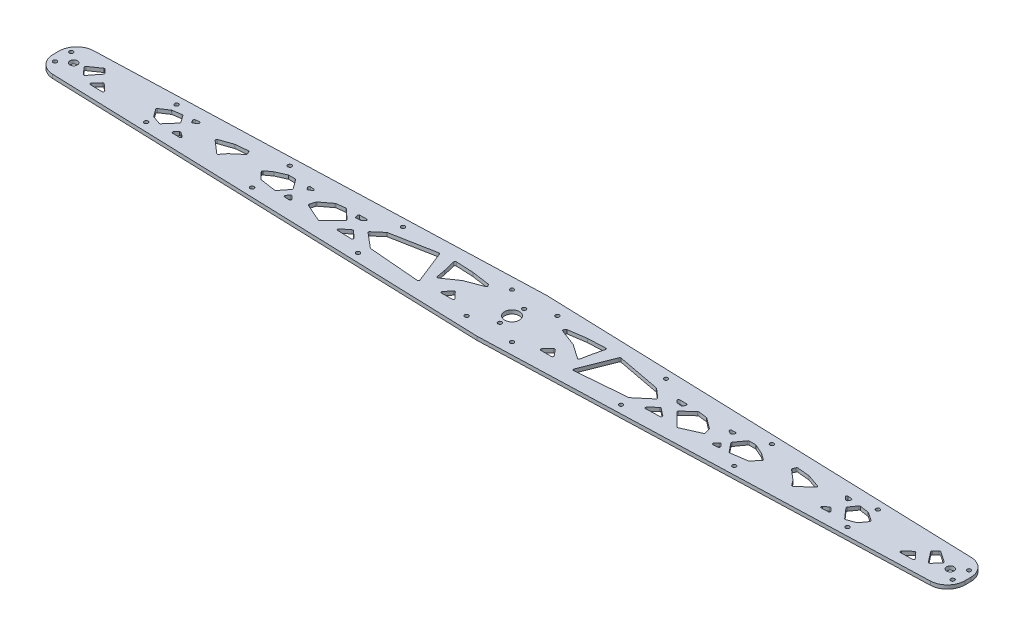
from build123d import *

# Parameters (mm, degrees)
BOSS_EXTRUDE1_DEPTH = 3.18
SKETCH3_R           = 6.35
SKETCH3_R_2         = 3.175
SKETCH3_R_3         = 1.65
CUT_EXTRUDE1_DEPTH  = 4.18
CUT_EXTRUDE8_DEPTH  = 4.18
SKETCH12_R          = 1.65
CUT_EXTRUDE9_DEPTH  = 4.18


with BuildPart() as part:
    # Sketch2 → Boss-Extrude1 (new body)
    with BuildSketch(Plane(origin=(0, 0, 0), x_dir=(1, 0, 0), z_dir=(0, 1, 0))):
        with BuildLine():
            Line((-375, 17.5), (0, 30))
            Line((0, 30), (375, 17.5))
            Line((375, 17.5), (375.499722453, 17.483342585))
            ThreePointArc((375.499722453, 17.483342585), (385.781832794, 12.920095592), (390, 2.49166898))
            Line((390, 2.49166898), (390, -2.49166898))
            ThreePointArc((390, -2.49166898), (385.781832794, -12.920095592), (375.499722453, -17.483342585))
            Line((375.499722453, -17.483342585), (375, -17.5))
            Line((375, -17.5), (0, -30))
            Line((0, -30), (-375, -17.5))
            Line((-375, -17.5), (-375.499722453, -17.483342585))
            ThreePointArc((-375.499722453, -17.483342585), (-385.781832794, -12.920095592), (-390, -2.49166898))
            Line((-390, -2.49166898), (-390, 2.49166898))
            ThreePointArc((-390, 2.49166898), (-385.781832794, 12.920095592), (-375.499722453, 17.483342585))
            Line((-375.499722453, 17.483342585), (-375, 17.5))
        make_face()
    extrude(amount=BOSS_EXTRUDE1_DEPTH)

    # Sketch3 → Cut-Extrude1 (cut, through all)
    with BuildSketch(Plane(origin=(0, 3.18, 0), x_dir=(1, 0, 0), z_dir=(0, 1, 0))):
        Circle(SKETCH3_R)
        with Locations((-375, 0)):
            Circle(SKETCH3_R_2)
        with Locations((-206.25, 16.125)):
            Circle(SKETCH3_R_3)
        with Locations((-112.5, -19.25)):
            Circle(SKETCH3_R_3)
        with Locations((375, 0)):
            Circle(SKETCH3_R_2)
        with Locations((-112.5, 19.25)):
            Circle(SKETCH3_R_3)
        with Locations((-206.25, -16.125)):
            Circle(SKETCH3_R_3)
        with Locations((112.5, -19.25)):
            Circle(SKETCH3_R_3)
        with Locations((112.5, 19.25)):
            Circle(SKETCH3_R_3)
        with Locations((206.25, -16.125)):
            Circle(SKETCH3_R_3)
        with Locations((206.25, 16.125)):
            Circle(SKETCH3_R_3)
        with Locations((-384, 7)):
            Circle(SKETCH3_R_3)
        with Locations((-384, -7)):
            Circle(SKETCH3_R_3)
        with Locations((384, -7)):
            Circle(SKETCH3_R_3)
        with Locations((384, 7)):
            Circle(SKETCH3_R_3)
        with Locations((-19.420687745, 19.420687745)):
            Circle(SKETCH3_R_3)
        with Locations((-19.420687745, -19.420687745)):
            Circle(SKETCH3_R_3)
        with Locations((19.420687745, -19.420687745)):
            Circle(SKETCH3_R_3)
        with Locations((19.420687745, 19.420687745)):
            Circle(SKETCH3_R_3)
        with Locations((-300, 13)):
            Circle(SKETCH3_R_3)
        with Locations((-300, -13)):
            Circle(SKETCH3_R_3)
        with Locations((300, -13)):
            Circle(SKETCH3_R_3)
        with Locations((300, 13)):
            Circle(SKETCH3_R_3)
    extrude(amount=-CUT_EXTRUDE1_DEPTH, mode=Mode.SUBTRACT)

    # Sketch11 → Cut-Extrude8 (cut, through all)
    with BuildSketch(Plane(origin=(0, 3.18, 0), x_dir=(1, 0, 0), z_dir=(0, 1, 0))):
        with BuildLine():
            Line((-46.955749346, -13.254199403), (-37.87504075, -13.254199403))
            ThreePointArc((-37.87504075, -13.254199403), (-36.95455324, -12.644971387), (-37.155639289, -11.559604889))
            Line((-37.155639289, -11.559604889), (-42.067554645, -6.472263986))
            ThreePointArc((-42.067554645, -6.472263986), (-42.827630249, -6.167686035), (-43.560434546, -6.533035888))
            Line((-43.560434546, -6.533035888), (-47.729227786, -11.620376792))
            ThreePointArc((-47.729227786, -11.620376792), (-47.859580804, -12.68208805), (-46.955749346, -13.254199403))
        make_face()
        with BuildLine():
            Line((-59.536816501, -3.515356838), (-47.468549241, 4.898167025))
            ThreePointArc((-47.468549241, 4.898167025), (-47.363497956, 4.962180575), (-47.251381641, 5.012810987))
            Line((-47.251381641, 5.012810987), (-32.914496504, 10.452279602))
            ThreePointArc((-32.914496504, 10.452279602), (-32.313794994, 11.092037289), (-32.44890253, 11.959146368))
            Line((-32.44890253, 11.959146368), (-33.152492574, 12.968368286))
            ThreePointArc((-33.152492574, 12.968368286), (-33.448046335, 13.247713619), (-33.830389761, 13.386275322))
            Line((-33.830389761, 13.386275322), (-49.020035845, 15.571979867))
            ThreePointArc((-49.020035845, 15.571979867), (-49.06816555, 15.57771866), (-49.116516797, 15.58111852))
            Line((-49.116516797, 15.58111852), (-63.942588973, 16.263044091))
            ThreePointArc((-63.942588973, 16.263044091), (-64.760029141, 15.900337127), (-64.960455814, 15.028790273))
            Line((-64.960455814, 15.028790273), (-62.531576105, 4.996583503))
            ThreePointArc((-62.531576105, 4.996583503), (-62.52527538, 4.968839122), (-62.519766476, 4.940926727))
            Line((-62.519766476, 4.940926727), (-61.092444735, -2.874685387))
            ThreePointArc((-61.092444735, -2.874685387), (-60.48952482, -3.619685515), (-59.536816501, -3.515356838))
        make_face()
        with BuildLine():
            Line((-65.867489279, -12.851084643), (-76.818791516, 14.810968515))
            ThreePointArc((-76.818791516, 14.810968515), (-77.266092019, 15.318773143), (-77.93434379, 15.42546359))
            Line((-77.93434379, 15.42546359), (-114.979478259, 8.421844862))
            ThreePointArc((-114.979478259, 8.421844862), (-115.227740664, 8.340150133), (-115.44635537, 8.196916545))
            Line((-115.44635537, 8.196916545), (-123.167009838, 1.546451805))
            ThreePointArc((-123.167009838, 1.546451805), (-123.514354617, 0.783798146), (-123.159419133, 0.024647435))
            Line((-123.159419133, 0.024647435), (-110.862565184, -10.35581369))
            ThreePointArc((-110.862565184, -10.35581369), (-110.599754836, -10.515737447), (-110.300767263, -10.588203424))
            Line((-110.300767263, -10.588203424), (-66.880530036, -14.21571199))
            ThreePointArc((-66.880530036, -14.21571199), (-65.994339866, -13.81524887), (-65.867489279, -12.851084643))
        make_face()
        with BuildLine():
            Line((-138.500363881, -9.512051857), (-132.205638285, -4.609617592))
            ThreePointArc((-132.205638285, -4.609617592), (-131.548188505, -4.399497492), (-130.911222966, -4.665327458))
            Line((-130.911222966, -4.665327458), (-125.244008956, -9.920736989))
            ThreePointArc((-125.244008956, -9.920736989), (-124.998535496, -11.032881643), (-125.953468681, -11.653547063))
            Line((-125.953468681, -11.653547063), (-137.915408287, -11.300571796))
            ThreePointArc((-137.915408287, -11.300571796), (-138.836369454, -10.611864392), (-138.500363881, -9.512051857))
        make_face()
        with BuildLine():
            Line((-139.739839999, 9.466665143), (-133.930891567, 9.592555667))
            ThreePointArc((-133.930891567, 9.592555667), (-132.974208512, 8.947395111), (-133.262475942, 7.83008741))
            Line((-133.262475942, 7.83008741), (-134.995827799, 6.360257908))
            ThreePointArc((-134.995827799, 6.360257908), (-135.241086847, 6.207097438), (-135.519914513, 6.130512433))
            Line((-135.519914513, 6.130512433), (-138.979079647, 5.70297517))
            ThreePointArc((-138.979079647, 5.70297517), (-139.629939754, 5.846302376), (-140.046194638, 6.366776619))
            Line((-140.046194638, 6.366776619), (-140.662626079, 8.138252861))
            ThreePointArc((-140.662626079, 8.138252861), (-140.539462824, 9.037411465), (-139.739839999, 9.466665143))
        make_face()
        with BuildLine():
            Line((-141.869121283, 0.703843181), (-150.293270264, 8.561291761))
            ThreePointArc((-150.293270264, 8.561291761), (-150.668059683, 8.78163118), (-151.100932501, 8.822099584))
            Line((-151.100932501, 8.822099584), (-158.46185294, 7.890337503))
            ThreePointArc((-158.46185294, 7.890337503), (-158.713075968, 7.824547363), (-158.938886877, 7.696286749))
            Line((-158.938886877, 7.696286749), (-167.835601055, 0.978159169))
            ThreePointArc((-167.835601055, 0.978159169), (-168.05379305, 0.751333346), (-168.190677878, 0.467925082))
            Line((-168.190677878, 0.467925082), (-169.532071457, -3.995753156))
            ThreePointArc((-169.532071457, -3.995753156), (-169.482672907, -4.701887684), (-168.978159747, -5.198408239))
            Line((-168.978159747, -5.198408239), (-153.825057905, -11.886351336))
            ThreePointArc((-153.825057905, -11.886351336), (-153.235786306, -11.95414059), (-152.711777672, -11.676199315))
            Line((-152.711777672, -11.676199315), (-141.841702337, -0.7321369))
            ThreePointArc((-141.841702337, -0.7321369), (-141.551385579, -0.00834171), (-141.869121283, 0.703843181))
        make_face()
        with BuildLine():
            Line((-182.755031755, -5.299067981), (-180.579398257, -7.823296737))
            ThreePointArc((-180.579398257, -7.823296737), (-180.443829145, -8.926135869), (-181.410839593, -9.473423661))
            Line((-181.410839593, -9.473423661), (-185.439828424, -9.174588009))
            ThreePointArc((-185.439828424, -9.174588009), (-186.28646803, -8.567815923), (-186.134274883, -7.537375127))
            Line((-186.134274883, -7.537375127), (-184.280919551, -5.311982023))
            ThreePointArc((-184.280919551, -5.311982023), (-183.520967893, -4.951970116), (-182.755031755, -5.299067981))
        make_face()
        with BuildLine():
            Line((-180.487436758, 6.129209035), (-178.34410904, 7.407639798))
            ThreePointArc((-178.34410904, 7.407639798), (-177.88764506, 8.514589055), (-178.82004379, 9.265807153))
            Line((-178.82004379, 9.265807153), (-181.742763405, 9.372060074))
            ThreePointArc((-181.742763405, 9.372060074), (-182.63306088, 8.893046831), (-182.650532608, 7.882216471))
            Line((-182.650532608, 7.882216471), (-181.871140711, 6.497532787))
            ThreePointArc((-181.871140711, 6.497532787), (-181.256931343, 6.02168626), (-180.487436758, 6.129209035))
        make_face()
        with BuildLine():
            Line((-193.789039066, -8.041405278), (-187.852068886, -0.594564861))
            ThreePointArc((-187.852068886, -0.594564861), (-187.634249822, 0.00587827), (-187.824300509, 0.615679742))
            Line((-187.824300509, 0.615679742), (-193.434660528, 8.356209406))
            ThreePointArc((-193.434660528, 8.356209406), (-193.789848688, 8.660094071), (-194.244346721, 8.76934633))
            Line((-194.244346721, 8.76934633), (-199.70292112, 8.76934633))
            ThreePointArc((-199.70292112, 8.76934633), (-199.909407573, 8.74779579), (-200.106994237, 8.68407302))
            Line((-200.106994237, 8.68407302), (-208.420259277, 5.011755427))
            ThreePointArc((-208.420259277, 5.011755427), (-208.514430087, 4.964065639), (-208.603049236, 4.90671493))
            Line((-208.603049236, 4.90671493), (-213.928370429, 1.046905536))
            ThreePointArc((-213.928370429, 1.046905536), (-214.336865254, 0.333462004), (-214.072627838, -0.445029026))
            Line((-214.072627838, -0.445029026), (-208.756796528, -6.141654092))
            ThreePointArc((-208.756796528, -6.141654092), (-208.489458004, -6.345355097), (-208.169728821, -6.448975729))
            Line((-208.169728821, -6.448975729), (-194.715009659, -8.407593757))
            ThreePointArc((-194.715009659, -8.407593757), (-194.203204992, -8.347947697), (-193.789039066, -8.041405278))
        make_face()
        with BuildLine():
            Line((-256.671139357, 4.718751255), (-245.67497638, 8.531374359))
            ThreePointArc((-245.67497638, 8.531374359), (-245.560909702, 8.563492446), (-245.443844553, 8.581891611))
            Line((-245.443844553, 8.581891611), (-235.114669132, 9.582900663))
            ThreePointArc((-235.114669132, 9.582900663), (-234.507333866, 9.447217919), (-234.097843596, 8.978620382))
            Line((-234.097843596, 8.978620382), (-233.190223738, 6.842502951))
            ThreePointArc((-233.190223738, 6.842502951), (-233.137214687, 6.222230535), (-233.461435256, 5.690790178))
            Line((-233.461435256, 5.690790178), (-241.684376578, -1.326788715))
            ThreePointArc((-241.684376578, -1.326788715), (-241.760643057, -1.399139955), (-241.828892701, -1.479097843))
            Line((-241.828892701, -1.479097843), (-245.184318041, -5.856705737))
            ThreePointArc((-245.184318041, -5.856705737), (-245.877859549, -6.24333317), (-246.634530886, -6.002648555))
            Line((-246.634530886, -6.002648555), (-257.000090234, 3.019641763))
            ThreePointArc((-257.000090234, 3.019641763), (-257.325318633, 3.964004117), (-256.671139357, 4.718751255))
        make_face()
        with BuildLine():
            Line((-281.137073769, -8.153694647), (-278.818258184, -5.834879062))
            ThreePointArc((-278.818258184, -5.834879062), (-278.197065936, -5.545683332), (-277.535535613, -5.724265559))
            Line((-277.535535613, -5.724265559), (-273.998540412, -8.214053722))
            ThreePointArc((-273.998540412, -8.214053722), (-273.625321962, -9.34754859), (-274.603340844, -10.031348044))
            Line((-274.603340844, -10.031348044), (-280.459151631, -9.860375466))
            ThreePointArc((-280.459151631, -9.860375466), (-281.359332965, -9.229961123), (-281.137073769, -8.153694647))
        make_face()
        with BuildLine():
            Line((-280.723932944, 9.802625591), (-277.488789213, 10.127315226))
            ThreePointArc((-277.488789213, 10.127315226), (-276.467186027, 9.520118535), (-276.747414613, 8.365201728))
            Line((-276.747414613, 8.365201728), (-279.104707894, 6.393867718))
            ThreePointArc((-279.104707894, 6.393867718), (-279.937308548, 6.179406901), (-280.628653906, 6.690541801))
            Line((-280.628653906, 6.690541801), (-281.506504356, 8.337186176))
            ThreePointArc((-281.506504356, 8.337186176), (-281.506173293, 9.278682803), (-280.723932944, 9.802625591))
        make_face()
        with BuildLine():
            Line((-290.168206163, 8.025157975), (-297.744296977, 6.8636667))
            ThreePointArc((-297.744296977, 6.8636667), (-297.954032467, 6.807674803), (-298.146743207, 6.707741631))
            Line((-298.146743207, 6.707741631), (-305.204875906, 2.011065969))
            ThreePointArc((-305.204875906, 2.011065969), (-305.634726846, 1.357607704), (-305.462686612, 0.594599387))
            Line((-305.462686612, 0.594599387), (-301.147906841, -5.403825691))
            ThreePointArc((-301.147906841, -5.403825691), (-300.937309283, -5.618984629), (-300.672216228, -5.761709442))
            Line((-300.672216228, -5.761709442), (-293.667939867, -8.26130378))
            ThreePointArc((-293.667939867, -8.26130378), (-293.079312884, -8.287070959), (-292.57834751, -7.976942974))
            Line((-292.57834751, -7.976942974), (-285.112364404, 0.57945318))
            ThreePointArc((-285.112364404, 0.57945318), (-284.867009214, 1.188798819), (-285.052655481, 1.818907335))
            Line((-285.052655481, 1.818907335), (-289.203471205, 7.618697534))
            ThreePointArc((-289.203471205, 7.618697534), (-289.628401701, 7.958254589), (-290.168206163, 8.025157975))
        make_face()
        with BuildLine():
            Line((-360.721388989, -4.456205516), (-353.816399288, 4.292749779))
            ThreePointArc((-353.816399288, 4.292749779), (-353.602294182, 4.955196144), (-353.872418696, 5.596841629))
            Line((-353.872418696, 5.596841629), (-356.779527483, 8.692466622))
            ThreePointArc((-356.779527483, 8.692466622), (-357.402501606, 9.002272333), (-358.07677814, 8.830727899))
            Line((-358.07677814, 8.830727899), (-367.037687971, 2.641731163))
            ThreePointArc((-367.037687971, 2.641731163), (-367.461830786, 1.941643396), (-367.221019381, 1.159320012))
            Line((-367.221019381, 1.159320012), (-362.257990463, -4.496263538))
            ThreePointArc((-362.257990463, -4.496263538), (-361.480302142, -4.836336586), (-360.721388989, -4.456205516))
        make_face()
        with BuildLine():
            Line((-352.372806931, -7.394203651), (-347.919490428, -2.485222451))
            ThreePointArc((-347.919490428, -2.485222451), (-347.227457966, -2.158301193), (-346.506948881, -2.416473802))
            Line((-346.506948881, -2.416473802), (-340.919616542, -7.485175085))
            ThreePointArc((-340.919616542, -7.485175085), (-340.661495607, -8.593335713), (-341.607418325, -9.225693685))
            Line((-341.607418325, -9.225693685), (-351.648067167, -9.065973602))
            ThreePointArc((-351.648067167, -9.065973602), (-352.549656155, -8.463848976), (-352.372806931, -7.394203651))
        make_face()
        with BuildLine():
            Line((37.155639289, -11.559604889), (42.067554645, -6.472263986))
            ThreePointArc((42.067554645, -6.472263986), (42.827630249, -6.167686035), (43.560434546, -6.533035888))
            Line((43.560434546, -6.533035888), (47.729227786, -11.620376792))
            ThreePointArc((47.729227786, -11.620376792), (47.859580804, -12.68208805), (46.955749346, -13.254199403))
            Line((46.955749346, -13.254199403), (37.87504075, -13.254199403))
            ThreePointArc((37.87504075, -13.254199403), (36.95455324, -12.644971387), (37.155639289, -11.559604889))
        make_face()
        with BuildLine():
            Line((64.960455814, 15.028790273), (62.531576105, 4.996583503))
            ThreePointArc((62.531576105, 4.996583503), (62.52527538, 4.968839122), (62.519766476, 4.940926727))
            Line((62.519766476, 4.940926727), (61.092444735, -2.874685387))
            ThreePointArc((61.092444735, -2.874685387), (60.48952482, -3.619685515), (59.536816501, -3.515356838))
            Line((59.536816501, -3.515356838), (47.468549241, 4.898167025))
            ThreePointArc((47.468549241, 4.898167025), (47.363497956, 4.962180575), (47.251381641, 5.012810987))
            Line((47.251381641, 5.012810987), (32.914496504, 10.452279602))
            ThreePointArc((32.914496504, 10.452279602), (32.313794994, 11.092037289), (32.44890253, 11.959146368))
            Line((32.44890253, 11.959146368), (33.152492574, 12.968368286))
            ThreePointArc((33.152492574, 12.968368286), (33.448046335, 13.247713619), (33.830389761, 13.386275322))
            Line((33.830389761, 13.386275322), (49.020035845, 15.571979867))
            ThreePointArc((49.020035845, 15.571979867), (49.06816555, 15.57771866), (49.116516797, 15.58111852))
            Line((49.116516797, 15.58111852), (63.942588973, 16.263044091))
            ThreePointArc((63.942588973, 16.263044091), (64.760029141, 15.900337127), (64.960455814, 15.028790273))
        make_face()
        with BuildLine():
            Line((123.159419133, 0.024647435), (110.862565184, -10.35581369))
            ThreePointArc((110.862565184, -10.35581369), (110.599754836, -10.515737447), (110.300767263, -10.588203424))
            Line((110.300767263, -10.588203424), (66.880530036, -14.21571199))
            ThreePointArc((66.880530036, -14.21571199), (65.994339866, -13.81524887), (65.867489279, -12.851084643))
            Line((65.867489279, -12.851084643), (76.818791516, 14.810968515))
            ThreePointArc((76.818791516, 14.810968515), (77.266092019, 15.318773143), (77.93434379, 15.42546359))
            Line((77.93434379, 15.42546359), (114.979478259, 8.421844862))
            ThreePointArc((114.979478259, 8.421844862), (115.227740664, 8.340150133), (115.44635537, 8.196916545))
            Line((115.44635537, 8.196916545), (123.167009838, 1.546451805))
            ThreePointArc((123.167009838, 1.546451805), (123.514354617, 0.783798146), (123.159419133, 0.024647435))
        make_face()
        with BuildLine():
            Line((135.519914513, 6.130512433), (138.979079647, 5.70297517))
            ThreePointArc((138.979079647, 5.70297517), (139.629939754, 5.846302376), (140.046194638, 6.366776619))
            Line((140.046194638, 6.366776619), (140.662626079, 8.138252861))
            ThreePointArc((140.662626079, 8.138252861), (140.539462824, 9.037411465), (139.739839999, 9.466665143))
            Line((139.739839999, 9.466665143), (133.930891567, 9.592555667))
            ThreePointArc((133.930891567, 9.592555667), (132.974208512, 8.947395111), (133.262475942, 7.83008741))
            Line((133.262475942, 7.83008741), (134.995827799, 6.360257908))
            ThreePointArc((134.995827799, 6.360257908), (135.241086847, 6.207097438), (135.519914513, 6.130512433))
        make_face()
        with BuildLine():
            Line((130.911222966, -4.665327458), (125.244008956, -9.920736989))
            ThreePointArc((125.244008956, -9.920736989), (124.998535496, -11.032881643), (125.953468681, -11.653547063))
            Line((125.953468681, -11.653547063), (137.915408287, -11.300571796))
            ThreePointArc((137.915408287, -11.300571796), (138.836369454, -10.611864392), (138.500363881, -9.512051857))
            Line((138.500363881, -9.512051857), (132.205638285, -4.609617592))
            ThreePointArc((132.205638285, -4.609617592), (131.548188505, -4.399497492), (130.911222966, -4.665327458))
        make_face()
        with BuildLine():
            Line((168.978159747, -5.198408239), (153.825057905, -11.886351336))
            ThreePointArc((153.825057905, -11.886351336), (153.235786306, -11.95414059), (152.711777672, -11.676199315))
            Line((152.711777672, -11.676199315), (141.841702337, -0.7321369))
            ThreePointArc((141.841702337, -0.7321369), (141.551385579, -0.00834171), (141.869121283, 0.703843181))
            Line((141.869121283, 0.703843181), (150.293270264, 8.561291761))
            ThreePointArc((150.293270264, 8.561291761), (150.668059683, 8.78163118), (151.100932501, 8.822099584))
            Line((151.100932501, 8.822099584), (158.46185294, 7.890337503))
            ThreePointArc((158.46185294, 7.890337503), (158.713075968, 7.824547363), (158.938886877, 7.696286749))
            Line((158.938886877, 7.696286749), (167.835601055, 0.978159169))
            ThreePointArc((167.835601055, 0.978159169), (168.05379305, 0.751333346), (168.190677878, 0.467925082))
            Line((168.190677878, 0.467925082), (169.532071457, -3.995753156))
            ThreePointArc((169.532071457, -3.995753156), (169.482672907, -4.701887684), (168.978159747, -5.198408239))
        make_face()
        with BuildLine():
            Line((181.871140711, 6.497532787), (182.650532608, 7.882216471))
            ThreePointArc((182.650532608, 7.882216471), (182.63306088, 8.893046831), (181.742763405, 9.372060074))
            Line((181.742763405, 9.372060074), (178.82004379, 9.265807153))
            ThreePointArc((178.82004379, 9.265807153), (177.88764506, 8.514589055), (178.34410904, 7.407639798))
            Line((178.34410904, 7.407639798), (180.487436758, 6.129209035))
            ThreePointArc((180.487436758, 6.129209035), (181.256931343, 6.02168626), (181.871140711, 6.497532787))
        make_face()
        with BuildLine():
            Line((181.410839593, -9.473423661), (185.439828424, -9.174588009))
            ThreePointArc((185.439828424, -9.174588009), (186.28646803, -8.567815923), (186.134274883, -7.537375127))
            Line((186.134274883, -7.537375127), (184.280919551, -5.311982023))
            ThreePointArc((184.280919551, -5.311982023), (183.520967893, -4.951970116), (182.755031755, -5.299067981))
            Line((182.755031755, -5.299067981), (180.579398257, -7.823296737))
            ThreePointArc((180.579398257, -7.823296737), (180.443829145, -8.926135869), (181.410839593, -9.473423661))
        make_face()
        with BuildLine():
            Line((214.072627838, -0.445029026), (208.756796528, -6.141654092))
            ThreePointArc((208.756796528, -6.141654092), (208.489458004, -6.345355097), (208.169728821, -6.448975729))
            Line((208.169728821, -6.448975729), (194.715009659, -8.407593757))
            ThreePointArc((194.715009659, -8.407593757), (194.203204992, -8.347947697), (193.789039066, -8.041405278))
            Line((193.789039066, -8.041405278), (187.852068886, -0.594564861))
            ThreePointArc((187.852068886, -0.594564861), (187.634249822, 0.00587827), (187.824300509, 0.615679742))
            Line((187.824300509, 0.615679742), (193.434660528, 8.356209406))
            ThreePointArc((193.434660528, 8.356209406), (193.789848688, 8.660094071), (194.244346721, 8.76934633))
            Line((194.244346721, 8.76934633), (199.70292112, 8.76934633))
            ThreePointArc((199.70292112, 8.76934633), (199.909407573, 8.74779579), (200.106994237, 8.68407302))
            Line((200.106994237, 8.68407302), (208.420259277, 5.011755427))
            ThreePointArc((208.420259277, 5.011755427), (208.514430087, 4.964065639), (208.603049236, 4.90671493))
            Line((208.603049236, 4.90671493), (213.928370429, 1.046905536))
            ThreePointArc((213.928370429, 1.046905536), (214.336865254, 0.333462004), (214.072627838, -0.445029026))
        make_face()
        with BuildLine():
            Line((241.828892701, -1.479097843), (245.184318041, -5.856705737))
            ThreePointArc((245.184318041, -5.856705737), (245.877859549, -6.24333317), (246.634530886, -6.002648555))
            Line((246.634530886, -6.002648555), (257.000090234, 3.019641763))
            ThreePointArc((257.000090234, 3.019641763), (257.325318633, 3.964004117), (256.671139357, 4.718751255))
            Line((256.671139357, 4.718751255), (245.67497638, 8.531374359))
            ThreePointArc((245.67497638, 8.531374359), (245.560909702, 8.563492446), (245.443844553, 8.581891611))
            Line((245.443844553, 8.581891611), (235.114669132, 9.582900663))
            ThreePointArc((235.114669132, 9.582900663), (234.507333866, 9.447217919), (234.097843596, 8.978620382))
            Line((234.097843596, 8.978620382), (233.190223738, 6.842502951))
            ThreePointArc((233.190223738, 6.842502951), (233.137214687, 6.222230535), (233.461435256, 5.690790178))
            Line((233.461435256, 5.690790178), (241.684376578, -1.326788715))
            ThreePointArc((241.684376578, -1.326788715), (241.760643057, -1.399139955), (241.828892701, -1.479097843))
        make_face()
        with BuildLine():
            Line((276.747414613, 8.365201728), (279.104707894, 6.393867718))
            ThreePointArc((279.104707894, 6.393867718), (279.937308548, 6.179406901), (280.628653906, 6.690541801))
            Line((280.628653906, 6.690541801), (281.506504356, 8.337186176))
            ThreePointArc((281.506504356, 8.337186176), (281.506173293, 9.278682803), (280.723932944, 9.802625591))
            Line((280.723932944, 9.802625591), (277.488789213, 10.127315226))
            ThreePointArc((277.488789213, 10.127315226), (276.467186027, 9.520118535), (276.747414613, 8.365201728))
        make_face()
        with BuildLine():
            Line((277.535535613, -5.724265559), (273.998540412, -8.214053722))
            ThreePointArc((273.998540412, -8.214053722), (273.625321962, -9.34754859), (274.603340844, -10.031348044))
            Line((274.603340844, -10.031348044), (280.459151631, -9.860375466))
            ThreePointArc((280.459151631, -9.860375466), (281.359332965, -9.229961123), (281.137073769, -8.153694647))
            Line((281.137073769, -8.153694647), (278.818258184, -5.834879062))
            ThreePointArc((278.818258184, -5.834879062), (278.197065936, -5.545683332), (277.535535613, -5.724265559))
        make_face()
        with BuildLine():
            Line((292.57834751, -7.976942974), (285.112364404, 0.57945318))
            ThreePointArc((285.112364404, 0.57945318), (284.867009214, 1.188798819), (285.052655481, 1.818907335))
            Line((285.052655481, 1.818907335), (289.203471205, 7.618697534))
            ThreePointArc((289.203471205, 7.618697534), (289.628401701, 7.958254589), (290.168206163, 8.025157975))
            Line((290.168206163, 8.025157975), (297.744296977, 6.8636667))
            ThreePointArc((297.744296977, 6.8636667), (297.954032467, 6.807674803), (298.146743207, 6.707741631))
            Line((298.146743207, 6.707741631), (305.204875906, 2.011065969))
            ThreePointArc((305.204875906, 2.011065969), (305.634726846, 1.357607704), (305.462686612, 0.594599387))
            Line((305.462686612, 0.594599387), (301.147906841, -5.403825691))
            ThreePointArc((301.147906841, -5.403825691), (300.937309283, -5.618984629), (300.672216228, -5.761709442))
            Line((300.672216228, -5.761709442), (293.667939867, -8.26130378))
            ThreePointArc((293.667939867, -8.26130378), (293.079312884, -8.287070959), (292.57834751, -7.976942974))
        make_face()
        with BuildLine():
            Line((358.07677814, 8.830727899), (367.037687971, 2.641731163))
            ThreePointArc((367.037687971, 2.641731163), (367.461830786, 1.941643396), (367.221019381, 1.159320012))
            Line((367.221019381, 1.159320012), (362.257990463, -4.496263538))
            ThreePointArc((362.257990463, -4.496263538), (361.480302142, -4.836336586), (360.721388989, -4.456205516))
            Line((360.721388989, -4.456205516), (353.816399288, 4.292749779))
            ThreePointArc((353.816399288, 4.292749779), (353.602294182, 4.955196144), (353.872418696, 5.596841629))
            Line((353.872418696, 5.596841629), (356.779527483, 8.692466622))
            ThreePointArc((356.779527483, 8.692466622), (357.402501606, 9.002272333), (358.07677814, 8.830727899))
        make_face()
        with BuildLine():
            Line((346.506948881, -2.416473802), (340.919616542, -7.485175085))
            ThreePointArc((340.919616542, -7.485175085), (340.661495607, -8.593335713), (341.607418325, -9.225693685))
            Line((341.607418325, -9.225693685), (351.648067167, -9.065973602))
            ThreePointArc((351.648067167, -9.065973602), (352.549656155, -8.463848976), (352.372806931, -7.394203651))
            Line((352.372806931, -7.394203651), (347.919490428, -2.485222451))
            ThreePointArc((347.919490428, -2.485222451), (347.227457966, -2.158301193), (346.506948881, -2.416473802))
        make_face()
    extrude(amount=-CUT_EXTRUDE8_DEPTH, mode=Mode.SUBTRACT)

    # Sketch12 → Cut-Extrude9 (cut, through all)
    with BuildSketch(Plane(origin=(0, 3.18, 0), x_dir=(1, 0, 0), z_dir=(0, 1, 0))):
        with Locations((0, 10.31875)):
            Circle(SKETCH12_R)
        with Locations((0, -10.31875)):
            Circle(SKETCH12_R)
    extrude(amount=-CUT_EXTRUDE9_DEPTH, mode=Mode.SUBTRACT)


solid = part.part
